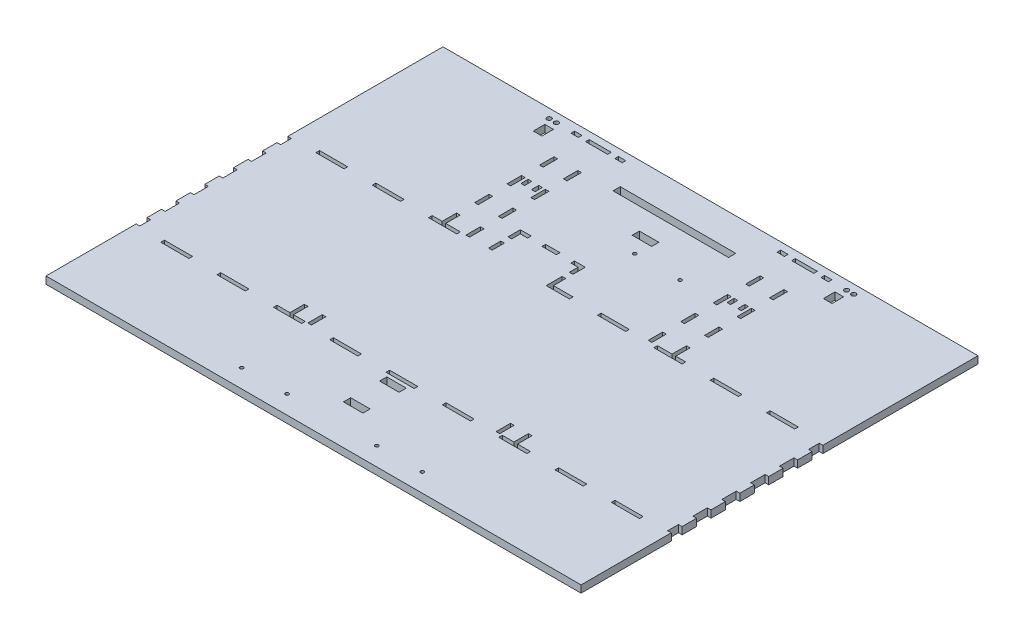
from build123d import *

# Parameters (mm, degrees)
SKETCH1_W                   = 470.789
SKETCH1_H                   = 139.7
BOSS_EXTRUDE1_DEPTH         = 6.35
SKETCH2_W                   = 470.789
SKETCH2_H                   = 139.7
SKETCH2_W_2                 = 464.439
SKETCH2_H_2                 = 133.35
BOSS_EXTRUDE2_DEPTH         = 298.45
SKETCH3_W                   = 5.588
SKETCH3_H                   = 16.933333333
SKETCH3_H_2                 = 16.933333334
DOOR_SLOT_DEPTH             = 12.7
SKETCH4_W                   = 6.35
SKETCH4_H                   = 15.875
DOOR_GUIDE_HOLES_DEPTH      = 3.175
LEVERHOLE_CUT_REACH         = 141.7
LEVER_HOLES_R               = 1.5
LEVER_HOLES_W               = 25.4
LEVER_HOLES_H               = 7.62
LEVER_HOLES_W_2             = 4
LEVER_HOLES_H_2             = 6.35
LEVER_HOLES_2_R             = 1.5
LBRACKET_THRU_HOLES_DEPTH   = 140.7
SKETCH8_R                   = 3.175
TETHER_HOLE_DEPTH           = 471.789
DOOR_GUIDE_ROOF_SLOTS_REACH = 141.7
SKETCH16_W                  = 9.525
SKETCH16_H                  = 9.271
SKETCH17_W                  = 470.789
SKETCH17_H                  = 298.45
CUT_EXTRUDE10_DEPTH         = 140.7
BOTTOM_W                    = 24.778368421
BOTTOM_H                    = 3.175
BOTTOM_W_2                  = 24.778368422
BOTTOM_W_3                  = 3.175
BOTTOM_H_2                  = 9.525
BOTTOM_H_3                  = 12.7
CUT_EXTRUDE11_DEPTH         = 7.35
SKETCH18_W                  = 470.789
SKETCH18_H                  = 76.2
SKETCH18_W_2                = 6.477
SKETCH18_H_2                = 3.175
SKETCH18_W_3                = 19.431
SKETCH18_W_4                = 3.175
SKETCH18_H_3                = 12.7
SKETCH18_W_5                = 12.7
BOSS_EXTRUDE3_DEPTH         = 6.35
SKETCH19_R                  = 1.499997
SKETCH19_R_2                = 2
SKETCH19_W                  = 3.175
SKETCH19_H                  = 6.35
CUT_EXTRUDE12_DEPTH         = 7.35
SKETCH20_W                  = 3.175
SKETCH20_H                  = 12.7
CUT_EXTRUDE13_DEPTH         = 7.35
SKETCH21_W                  = 7.62
SKETCH21_H                  = 10.16
SKETCH21_W_2                = 17.145
SKETCH21_H_2                = 6.35
SKETCH21_W_3                = 101.6
WIRE_HOLES_DEPTH            = 7.35


with BuildPart() as part:
    # Sketch1 → Boss-Extrude1 (new body)
    with BuildSketch(Plane(origin=(0, 0, 0), x_dir=(1, 0, 0), z_dir=(0, 1, 0))):
        Rectangle(SKETCH1_W, SKETCH1_H)
    extrude(amount=BOSS_EXTRUDE1_DEPTH)

    # Sketch2 → Boss-Extrude2 (add)
    with BuildSketch(Plane(origin=(0, 6.35, 0), x_dir=(1, 0, 0), z_dir=(0, 1, 0))):
        Rectangle(SKETCH2_W, SKETCH2_H)
        Rectangle(SKETCH2_W_2, SKETCH2_H_2, mode=Mode.SUBTRACT)
    extrude(amount=BOSS_EXTRUDE2_DEPTH)

    # Sketch3 → Door Slot (cut)
    with BuildSketch(Plane.XY.offset(69.85)):
        with BuildLine():
            Line((70.1675, 292.354), (70.1675, 6.35))
            Line((70.1675, 6.35), (76.7715, 6.35))
            Line((76.7715, 6.35), (76.7715, 283.240675824))
            ThreePointArc((76.7715, 283.240675824), (77.515448776, 285.036727048), (79.3115, 285.780675824))
            Line((79.3115, 285.780675824), (89.7255, 285.780675824))
            Line((89.7255, 285.780675824), (89.7255, 292.354))
            Line((89.7255, 292.354), (70.1675, 292.354))
        make_face()
        with Locations((60.2615, 80.433333334)):
            Rectangle(SKETCH3_W, SKETCH3_H)
        with Locations((60.2615, 50.8)):
            Rectangle(SKETCH3_W, SKETCH3_H_2)
        with Locations((60.2615, 21.166666667)):
            Rectangle(SKETCH3_W, SKETCH3_H)
        with BuildLine():
            Line((-76.7715, 283.240675824), (-76.7715, 6.35))
            Line((-76.7715, 6.35), (-70.1675, 6.35))
            Line((-70.1675, 6.35), (-70.1675, 292.354))
            Line((-70.1675, 292.354), (-89.7255, 292.354))
            Line((-89.7255, 292.354), (-89.7255, 285.780675824))
            Line((-89.7255, 285.780675824), (-79.3115, 285.780675824))
            ThreePointArc((-79.3115, 285.780675824), (-77.515448776, 285.036727048), (-76.7715, 283.240675824))
        make_face()
        with Locations((-60.2615, 80.433333334)):
            Rectangle(SKETCH3_W, SKETCH3_H)
        with Locations((-60.2615, 50.8)):
            Rectangle(SKETCH3_W, SKETCH3_H_2)
        with Locations((-60.2615, 21.166666667)):
            Rectangle(SKETCH3_W, SKETCH3_H)
    extrude(amount=-DOOR_SLOT_DEPTH, mode=Mode.SUBTRACT)

    # Sketch4 → Door Guide Holes (cut)
    with BuildSketch(Plane.XY.offset(-66.675)):
        with Locations((66.9925, 255.5875)):
            Rectangle(SKETCH4_W, SKETCH4_H)
        with Locations((66.9925, 227.0125)):
            Rectangle(SKETCH4_W, SKETCH4_H)
        with Locations((66.9925, 198.4375)):
            Rectangle(SKETCH4_W, SKETCH4_H)
        with Locations((66.9925, 169.8625)):
            Rectangle(SKETCH4_W, SKETCH4_H)
        with Locations((66.9925, 141.2875)):
            Rectangle(SKETCH4_W, SKETCH4_H)
        with Locations((66.9925, 112.7125)):
            Rectangle(SKETCH4_W, SKETCH4_H)
        with Locations((66.9925, 84.1375)):
            Rectangle(SKETCH4_W, SKETCH4_H)
        with Locations((66.9925, 55.5625)):
            Rectangle(SKETCH4_W, SKETCH4_H)
        with Locations((66.9925, 26.9875)):
            Rectangle(SKETCH4_W, SKETCH4_H)
        with Locations((-92.9005, 284.1625)):
            Rectangle(SKETCH4_W, SKETCH4_H)
        with Locations((-92.9005, 255.5875)):
            Rectangle(SKETCH4_W, SKETCH4_H)
        with Locations((-92.9005, 227.0125)):
            Rectangle(SKETCH4_W, SKETCH4_H)
        with Locations((-92.9005, 198.4375)):
            Rectangle(SKETCH4_W, SKETCH4_H)
        with Locations((-92.9005, 169.8625)):
            Rectangle(SKETCH4_W, SKETCH4_H)
        with Locations((-92.9005, 141.2875)):
            Rectangle(SKETCH4_W, SKETCH4_H)
        with Locations((-92.9005, 112.7125)):
            Rectangle(SKETCH4_W, SKETCH4_H)
        with Locations((-92.9005, 84.1375)):
            Rectangle(SKETCH4_W, SKETCH4_H)
        with Locations((-92.9005, 55.5625)):
            Rectangle(SKETCH4_W, SKETCH4_H)
        with Locations((-92.9005, 26.9875)):
            Rectangle(SKETCH4_W, SKETCH4_H)
        with Locations((92.9005, 284.1625)):
            Rectangle(SKETCH4_W, SKETCH4_H)
        with Locations((92.9005, 255.5875)):
            Rectangle(SKETCH4_W, SKETCH4_H)
        with Locations((92.9005, 227.0125)):
            Rectangle(SKETCH4_W, SKETCH4_H)
        with Locations((92.9005, 198.4375)):
            Rectangle(SKETCH4_W, SKETCH4_H)
        with Locations((92.9005, 169.8625)):
            Rectangle(SKETCH4_W, SKETCH4_H)
        with Locations((92.9005, 141.2875)):
            Rectangle(SKETCH4_W, SKETCH4_H)
        with Locations((92.9005, 112.7125)):
            Rectangle(SKETCH4_W, SKETCH4_H)
        with Locations((92.9005, 84.1375)):
            Rectangle(SKETCH4_W, SKETCH4_H)
        with Locations((92.9005, 55.5625)):
            Rectangle(SKETCH4_W, SKETCH4_H)
        with Locations((92.9005, 26.9875)):
            Rectangle(SKETCH4_W, SKETCH4_H)
        with Locations((-66.9925, 284.1625)):
            Rectangle(SKETCH4_W, SKETCH4_H)
        with Locations((-66.9925, 255.5875)):
            Rectangle(SKETCH4_W, SKETCH4_H)
        with Locations((-66.9925, 227.0125)):
            Rectangle(SKETCH4_W, SKETCH4_H)
        with Locations((-66.9925, 198.4375)):
            Rectangle(SKETCH4_W, SKETCH4_H)
        with Locations((-66.9925, 169.8625)):
            Rectangle(SKETCH4_W, SKETCH4_H)
        with Locations((-66.9925, 141.2875)):
            Rectangle(SKETCH4_W, SKETCH4_H)
        with Locations((-66.9925, 112.7125)):
            Rectangle(SKETCH4_W, SKETCH4_H)
        with Locations((-66.9925, 84.1375)):
            Rectangle(SKETCH4_W, SKETCH4_H)
        with Locations((-66.9925, 55.5625)):
            Rectangle(SKETCH4_W, SKETCH4_H)
        with Locations((-66.9925, 26.9875)):
            Rectangle(SKETCH4_W, SKETCH4_H)
        with Locations((66.9925, 284.1625)):
            Rectangle(SKETCH4_W, SKETCH4_H)
    extrude(amount=-DOOR_GUIDE_HOLES_DEPTH, mode=Mode.SUBTRACT)

    # Lever Holes → LeverHole Cut (cut, up to next)
    with BuildSketch(Plane.XY.offset(-69.85), mode=Mode.PRIVATE) as leverhole_cut_sk1:
        with Locations((216.3445, 160.275)):
            Circle(LEVER_HOLES_R)
    leverhole_cut_tool1 = extrude(leverhole_cut_sk1.sketch, amount=LEVERHOLE_CUT_REACH, mode=Mode.PRIVATE) & part.part
    add(leverhole_cut_tool1.solids().sort_by_distance((216.3445, 160.275, -69.85))[0], mode=Mode.SUBTRACT)
    # Lever Holes → LeverHole Cut (cut, up to next)
    with BuildSketch(Plane.XY.offset(-69.85), mode=Mode.PRIVATE) as leverhole_cut_sk2:
        with Locations((216.3445, 144.525)):
            Circle(LEVER_HOLES_R)
    leverhole_cut_tool2 = extrude(leverhole_cut_sk2.sketch, amount=LEVERHOLE_CUT_REACH, mode=Mode.PRIVATE) & part.part
    add(leverhole_cut_tool2.solids().sort_by_distance((216.3445, 144.525, -69.85))[0], mode=Mode.SUBTRACT)
    # Lever Holes → LeverHole Cut (cut, up to next)
    with BuildSketch(Plane.XY.offset(-69.85), mode=Mode.PRIVATE) as leverhole_cut_sk3:
        with Locations((-216.3445, 160.275)):
            Circle(LEVER_HOLES_R)
    leverhole_cut_tool3 = extrude(leverhole_cut_sk3.sketch, amount=LEVERHOLE_CUT_REACH, mode=Mode.PRIVATE) & part.part
    add(leverhole_cut_tool3.solids().sort_by_distance((-216.3445, 160.275, -69.85))[0], mode=Mode.SUBTRACT)
    # Lever Holes → LeverHole Cut (cut, up to next)
    with BuildSketch(Plane.XY.offset(-69.85), mode=Mode.PRIVATE) as leverhole_cut_sk4:
        with Locations((-216.3445, 144.525)):
            Circle(LEVER_HOLES_R)
    leverhole_cut_tool4 = extrude(leverhole_cut_sk4.sketch, amount=LEVERHOLE_CUT_REACH, mode=Mode.PRIVATE) & part.part
    add(leverhole_cut_tool4.solids().sort_by_distance((-216.3445, 144.525, -69.85))[0], mode=Mode.SUBTRACT)
    # Lever Holes → LeverHole Cut (cut, up to next)
    with BuildSketch(Plane.XY.offset(-69.85), mode=Mode.PRIVATE) as leverhole_cut_sk5:
        with Locations((-40.5675, 33.8749894)):
            Rectangle(LEVER_HOLES_W, LEVER_HOLES_H)
    leverhole_cut_tool5 = extrude(leverhole_cut_sk5.sketch, amount=LEVERHOLE_CUT_REACH, mode=Mode.PRIVATE) & part.part
    add(leverhole_cut_tool5.solids().sort_by_distance((-40.5675, 33.874989, -69.85))[0], mode=Mode.SUBTRACT)
    # Lever Holes → LeverHole Cut (cut, up to next)
    with BuildSketch(Plane.XY.offset(-69.85), mode=Mode.PRIVATE) as leverhole_cut_sk6:
        with Locations((-51.8175, 13.175)):
            Rectangle(LEVER_HOLES_W_2, LEVER_HOLES_H_2)
    leverhole_cut_tool6 = extrude(leverhole_cut_sk6.sketch, amount=LEVERHOLE_CUT_REACH, mode=Mode.PRIVATE) & part.part
    add(leverhole_cut_tool6.solids().sort_by_distance((-51.8175, 13.175, -69.85))[0], mode=Mode.SUBTRACT)
    # Lever Holes → LeverHole Cut (cut, up to next)
    with BuildSketch(Plane.XY.offset(-69.85), mode=Mode.PRIVATE) as leverhole_cut_sk7:
        with Locations((-5.8175068, 13.175)):
            Rectangle(LEVER_HOLES_W_2, LEVER_HOLES_H_2)
    leverhole_cut_tool7 = extrude(leverhole_cut_sk7.sketch, amount=LEVERHOLE_CUT_REACH, mode=Mode.PRIVATE) & part.part
    add(leverhole_cut_tool7.solids().sort_by_distance((-5.817507, 13.175, -69.85))[0], mode=Mode.SUBTRACT)
    # Lever Holes → LeverHole Cut (cut, up to next)
    with BuildSketch(Plane.XY.offset(-69.85), mode=Mode.PRIVATE) as leverhole_cut_sk8:
        with Locations((5.8175068, 13.175)):
            Rectangle(LEVER_HOLES_W_2, LEVER_HOLES_H_2)
    leverhole_cut_tool8 = extrude(leverhole_cut_sk8.sketch, amount=LEVERHOLE_CUT_REACH, mode=Mode.PRIVATE) & part.part
    add(leverhole_cut_tool8.solids().sort_by_distance((5.817507, 13.175, -69.85))[0], mode=Mode.SUBTRACT)
    # Lever Holes → LeverHole Cut (cut, up to next)
    with BuildSketch(Plane.XY.offset(-69.85), mode=Mode.PRIVATE) as leverhole_cut_sk9:
        with Locations((40.5675, 33.8749894)):
            Rectangle(LEVER_HOLES_W, LEVER_HOLES_H)
    leverhole_cut_tool9 = extrude(leverhole_cut_sk9.sketch, amount=LEVERHOLE_CUT_REACH, mode=Mode.PRIVATE) & part.part
    add(leverhole_cut_tool9.solids().sort_by_distance((40.5675, 33.874989, -69.85))[0], mode=Mode.SUBTRACT)
    # Lever Holes → LeverHole Cut (cut, up to next)
    with BuildSketch(Plane.XY.offset(-69.85), mode=Mode.PRIVATE) as leverhole_cut_sk10:
        with Locations((51.8175, 13.175)):
            Rectangle(LEVER_HOLES_W_2, LEVER_HOLES_H_2)
    leverhole_cut_tool10 = extrude(leverhole_cut_sk10.sketch, amount=LEVERHOLE_CUT_REACH, mode=Mode.PRIVATE) & part.part
    add(leverhole_cut_tool10.solids().sort_by_distance((51.8175, 13.175, -69.85))[0], mode=Mode.SUBTRACT)

    # Lever Holes_2 → Lbracket Thru Holes (cut, through all)
    with BuildSketch(Plane.XY.offset(-69.85)):
        with Locations((-216.3445, 160.275)):
            Circle(LEVER_HOLES_2_R)
        with Locations((-216.3445, 144.525)):
            Circle(LEVER_HOLES_2_R)
        with Locations((216.3445, 160.275)):
            Circle(LEVER_HOLES_2_R)
        with Locations((216.3445, 144.525)):
            Circle(LEVER_HOLES_2_R)
    extrude(amount=LBRACKET_THRU_HOLES_DEPTH, mode=Mode.SUBTRACT)

    # Sketch8 → Tether Hole (cut, through all)
    with BuildSketch(Plane.ZY.offset(235.3945)):
        with Locations((0, 19.05)):
            Circle(SKETCH8_R)
    extrude(amount=-TETHER_HOLE_DEPTH, mode=Mode.SUBTRACT)

    # Sketch16 → Door Guide Roof Slots (cut, up to next)
    with BuildSketch(Plane.XY.offset(69.85), mode=Mode.PRIVATE) as door_guide_roof_slots_sk1:
        with Locations((52.578, 300.1645)):
            Rectangle(SKETCH16_W, SKETCH16_H)
    door_guide_roof_slots_tool1 = extrude(door_guide_roof_slots_sk1.sketch, amount=-DOOR_GUIDE_ROOF_SLOTS_REACH, mode=Mode.PRIVATE) & part.part
    add(door_guide_roof_slots_tool1.solids().sort_by_distance((52.578, 300.1645, 69.85))[0], mode=Mode.SUBTRACT)
    # Sketch16 → Door Guide Roof Slots (cut, up to next)
    with BuildSketch(Plane.XY.offset(69.85), mode=Mode.PRIVATE) as door_guide_roof_slots_sk2:
        with Locations((107.315, 300.1645)):
            Rectangle(SKETCH16_W, SKETCH16_H)
    door_guide_roof_slots_tool2 = extrude(door_guide_roof_slots_sk2.sketch, amount=-DOOR_GUIDE_ROOF_SLOTS_REACH, mode=Mode.PRIVATE) & part.part
    add(door_guide_roof_slots_tool2.solids().sort_by_distance((107.315, 300.1645, 69.85))[0], mode=Mode.SUBTRACT)
    # Sketch16 → Door Guide Roof Slots (cut, up to next)
    with BuildSketch(Plane.XY.offset(69.85), mode=Mode.PRIVATE) as door_guide_roof_slots_sk3:
        with Locations((-107.315, 300.1645)):
            Rectangle(SKETCH16_W, SKETCH16_H)
    door_guide_roof_slots_tool3 = extrude(door_guide_roof_slots_sk3.sketch, amount=-DOOR_GUIDE_ROOF_SLOTS_REACH, mode=Mode.PRIVATE) & part.part
    add(door_guide_roof_slots_tool3.solids().sort_by_distance((-107.315, 300.1645, 69.85))[0], mode=Mode.SUBTRACT)
    # Sketch16 → Door Guide Roof Slots (cut, up to next)
    with BuildSketch(Plane.XY.offset(69.85), mode=Mode.PRIVATE) as door_guide_roof_slots_sk4:
        with Locations((-52.578, 300.1645)):
            Rectangle(SKETCH16_W, SKETCH16_H)
    door_guide_roof_slots_tool4 = extrude(door_guide_roof_slots_sk4.sketch, amount=-DOOR_GUIDE_ROOF_SLOTS_REACH, mode=Mode.PRIVATE) & part.part
    add(door_guide_roof_slots_tool4.solids().sort_by_distance((-52.578, 300.1645, 69.85))[0], mode=Mode.SUBTRACT)

    # Sketch17 → Cut-Extrude10 (cut, through all)
    with BuildSketch(Plane.XY.offset(69.85)):
        with Locations((0, 155.575)):
            Rectangle(SKETCH17_W, SKETCH17_H)
    extrude(amount=-CUT_EXTRUDE10_DEPTH, mode=Mode.SUBTRACT)

    # Bottom → Cut-Extrude11 (cut, through all)
    with BuildSketch(Plane.XZ):
        with Locations((-198.226947369, 68.2625)):
            Rectangle(BOTTOM_W, BOTTOM_H)
        with Locations((-148.670210527, 68.2625)):
            Rectangle(BOTTOM_W, BOTTOM_H)
        with Locations((-99.113473685, 68.2625)):
            Rectangle(BOTTOM_W, BOTTOM_H)
        with Locations((-49.556736843, 68.2625)):
            Rectangle(BOTTOM_W, BOTTOM_H)
        with Locations((0, 68.2625)):
            Rectangle(BOTTOM_W_2, BOTTOM_H)
        with Locations((49.556736843, 68.2625)):
            Rectangle(BOTTOM_W, BOTTOM_H)
        with Locations((99.113473685, 68.2625)):
            Rectangle(BOTTOM_W, BOTTOM_H)
        with Locations((148.670210527, 68.2625)):
            Rectangle(BOTTOM_W, BOTTOM_H)
        with Locations((198.226947369, 68.2625)):
            Rectangle(BOTTOM_W, BOTTOM_H)
        with Locations((233.807, 61.9125)):
            Rectangle(BOTTOM_W_3, BOTTOM_H_2)
        with Locations((233.807, 38.1)):
            Rectangle(BOTTOM_W_3, BOTTOM_H_3)
        with Locations((233.807, 12.7)):
            Rectangle(BOTTOM_W_3, BOTTOM_H_3)
        with Locations((233.807, -12.7)):
            Rectangle(BOTTOM_W_3, BOTTOM_H_3)
        with Locations((233.807, -38.1)):
            Rectangle(BOTTOM_W_3, BOTTOM_H_3)
        with Locations((233.807, -61.9125)):
            Rectangle(BOTTOM_W_3, BOTTOM_H_2)
        with Locations((198.226947369, -68.2625)):
            Rectangle(BOTTOM_W, BOTTOM_H)
        with Locations((148.670210527, -68.2625)):
            Rectangle(BOTTOM_W, BOTTOM_H)
        with Locations((99.113473685, -68.2625)):
            Rectangle(BOTTOM_W, BOTTOM_H)
        with Locations((49.556736843, -68.2625)):
            Rectangle(BOTTOM_W, BOTTOM_H)
        with Locations((0, -68.2625)):
            Rectangle(BOTTOM_W_2, BOTTOM_H)
        with Locations((-99.113473685, -68.2625)):
            Rectangle(BOTTOM_W, BOTTOM_H)
        with Locations((-148.670210527, -68.2625)):
            Rectangle(BOTTOM_W, BOTTOM_H)
        with Locations((-198.226947369, -68.2625)):
            Rectangle(BOTTOM_W, BOTTOM_H)
        with Locations((-233.807, -61.9125)):
            Rectangle(BOTTOM_W_3, BOTTOM_H_2)
        with Locations((-233.807, -38.1)):
            Rectangle(BOTTOM_W_3, BOTTOM_H_3)
        with Locations((-233.807, -12.7)):
            Rectangle(BOTTOM_W_3, BOTTOM_H_3)
        with Locations((-233.807, 12.7)):
            Rectangle(BOTTOM_W_3, BOTTOM_H_3)
        with Locations((-233.807, 38.1)):
            Rectangle(BOTTOM_W_3, BOTTOM_H_3)
        with Locations((-233.807, 61.9125)):
            Rectangle(BOTTOM_W_3, BOTTOM_H_2)
    extrude(amount=-CUT_EXTRUDE11_DEPTH, mode=Mode.SUBTRACT)

    # Sketch18 → Boss-Extrude3 (add)
    with BuildSketch(Plane.XZ):
        with Locations((0, 107.95)):
            Rectangle(SKETCH18_W, SKETCH18_H)
        Polygon((-102.743, -69.85), (-235.3945, -69.85), (-235.3945, -203.2), (235.3945, -203.2), (235.3945, -69.85), (102.743, -69.85), (102.743, -82.55), (99.568, -82.55), (99.568, -69.85), (81.788, -69.85), (81.788, -82.55), (78.613, -82.55), (78.613, -69.85), (-4.795929074, -69.85), (-4.795929074, -80.6749974), (-7.970929074, -80.6749974), (-7.970929074, -66.675), (-12.389184211, -66.675), (-12.389184211, -69.85), (-58.770929074, -69.85), (-58.770929074, -80.6749974), (-61.945929074, -80.6749974), (-61.945929074, -69.85), (-78.613, -69.85), (-78.613, -82.55), (-81.788, -82.55), (-81.788, -69.85), (-99.568, -69.85), (-99.568, -82.55), (-102.743, -82.55), align=None)
        with Locations((-109.982, -195.2625)):
            Rectangle(SKETCH18_W_2, SKETCH18_H_2, mode=Mode.SUBTRACT)
        with Locations((-90.678, -195.2625)):
            Rectangle(SKETCH18_W_3, SKETCH18_H_2, mode=Mode.SUBTRACT)
        with Locations((-71.374, -195.2625)):
            Rectangle(SKETCH18_W_2, SKETCH18_H_2, mode=Mode.SUBTRACT)
        with Locations((71.374, -195.2625)):
            Rectangle(SKETCH18_W_2, SKETCH18_H_2, mode=Mode.SUBTRACT)
        with Locations((90.678, -195.2625)):
            Rectangle(SKETCH18_W_3, SKETCH18_H_2, mode=Mode.SUBTRACT)
        with Locations((109.982, -195.2625)):
            Rectangle(SKETCH18_W_2, SKETCH18_H_2, mode=Mode.SUBTRACT)
        with Locations((-101.1555, -161.925)):
            Rectangle(SKETCH18_W_4, SKETCH18_H_3, mode=Mode.SUBTRACT)
        with Locations((-80.2005, -161.925)):
            Rectangle(SKETCH18_W_4, SKETCH18_H_3, mode=Mode.SUBTRACT)
        with Locations((-101.1555, -133.35)):
            Rectangle(SKETCH18_W_4, SKETCH18_H_3, mode=Mode.SUBTRACT)
        with Locations((-80.2005, -133.35)):
            Rectangle(SKETCH18_W_4, SKETCH18_H_3, mode=Mode.SUBTRACT)
        with Locations((-101.1555, -104.775)):
            Rectangle(SKETCH18_W_4, SKETCH18_H_3, mode=Mode.SUBTRACT)
        with Locations((-80.2005, -104.775)):
            Rectangle(SKETCH18_W_4, SKETCH18_H_3, mode=Mode.SUBTRACT)
        with Locations((-33.370929074, -96.2624948)):
            Rectangle(SKETCH18_W_5, SKETCH18_H_2, mode=Mode.SUBTRACT)
        Polygon((-61.945929074, -97.8499948), (-61.945929074, -87.0249974), (-58.770929074, -87.0249974), (-58.770929074, -94.6749948), (-52.420929074, -94.6749948), (-52.420929074, -97.8499948), align=None, mode=Mode.SUBTRACT)
        Polygon((-14.320929074, -97.8499948), (-14.320929074, -94.6749948), (-7.970929074, -94.6749948), (-7.970929074, -87.0249974), (-4.795929074, -87.0249974), (-4.795929074, -97.8499948), align=None, mode=Mode.SUBTRACT)
        with Locations((80.2005, -161.925)):
            Rectangle(SKETCH18_W_4, SKETCH18_H_3, mode=Mode.SUBTRACT)
        with Locations((101.1555, -161.925)):
            Rectangle(SKETCH18_W_4, SKETCH18_H_3, mode=Mode.SUBTRACT)
        with Locations((80.2005, -133.35)):
            Rectangle(SKETCH18_W_4, SKETCH18_H_3, mode=Mode.SUBTRACT)
        with Locations((101.1555, -133.35)):
            Rectangle(SKETCH18_W_4, SKETCH18_H_3, mode=Mode.SUBTRACT)
        with Locations((80.2005, -104.775)):
            Rectangle(SKETCH18_W_4, SKETCH18_H_3, mode=Mode.SUBTRACT)
        with Locations((101.1555, -104.775)):
            Rectangle(SKETCH18_W_4, SKETCH18_H_3, mode=Mode.SUBTRACT)
    extrude(amount=-BOSS_EXTRUDE3_DEPTH)

    # Sketch19 → Cut-Extrude12 (cut, through all)
    with BuildSketch(Plane.XZ):
        with Locations((79.46649517, 129.85)):
            Circle(SKETCH19_R)
        with Locations((39.46650497, 129.85)):
            Circle(SKETCH19_R)
        with Locations((-39.46650497, 129.85)):
            Circle(SKETCH19_R)
        with Locations((-79.46649517, 129.85)):
            Circle(SKETCH19_R)
        with Locations((6.69920515, -129.85)):
            Circle(SKETCH19_R)
        with Locations((46.69919535, -129.85)):
            Circle(SKETCH19_R)
        with Locations((127.635, -195.2625)):
            Circle(SKETCH19_R_2)
        with Locations((133.985, -195.2625)):
            Circle(SKETCH19_R_2)
        with Locations((-127.635, -195.2625)):
            Circle(SKETCH19_R_2)
        with Locations((-133.985, -195.2625)):
            Circle(SKETCH19_R_2)
        with Locations((-86.0044, -136.525)):
            Rectangle(SKETCH19_W, SKETCH19_H)
        with Locations((-95.3516, -136.525)):
            Rectangle(SKETCH19_W, SKETCH19_H)
        with Locations((86.0044, -136.525)):
            Rectangle(SKETCH19_W, SKETCH19_H)
        with Locations((95.3516, -136.525)):
            Rectangle(SKETCH19_W, SKETCH19_H)
    extrude(amount=-CUT_EXTRUDE12_DEPTH, mode=Mode.SUBTRACT)

    # Sketch20 → Cut-Extrude13 (cut, through all)
    with BuildSketch(Plane(origin=(0, 0, 0), x_dir=(-1, 0, 0), z_dir=(0, -1, 0))):
        with Locations((-98.552, -60.325)):
            Rectangle(SKETCH20_W, SKETCH20_H)
        with Locations((-82.804, -60.325)):
            Rectangle(SKETCH20_W, SKETCH20_H)
        with Locations((82.804, -60.325)):
            Rectangle(SKETCH20_W, SKETCH20_H)
        with Locations((98.552, -60.325)):
            Rectangle(SKETCH20_W, SKETCH20_H)
    extrude(amount=-CUT_EXTRUDE13_DEPTH, mode=Mode.SUBTRACT)

    # Sketch21 → Wire Holes (cut, through all)
    with BuildSketch(Plane.XZ):
        with Locations((-127.635, -183.8325)):
            Rectangle(SKETCH21_W, SKETCH21_H)
        with Locations((127.635, -183.8325)):
            Rectangle(SKETCH21_W, SKETCH21_H)
        with Locations((0, 107.95)):
            Rectangle(SKETCH21_W_2, SKETCH21_H_2)
        with Locations((0, 76.2)):
            Rectangle(SKETCH21_W_2, SKETCH21_H_2)
        with Locations((0, -171.45)):
            Rectangle(SKETCH21_W_3, SKETCH21_H_2)
        with Locations((0, -146.05)):
            Rectangle(SKETCH21_W_2, SKETCH21_H_2)
    extrude(amount=-WIRE_HOLES_DEPTH, mode=Mode.SUBTRACT)


solid = part.part
